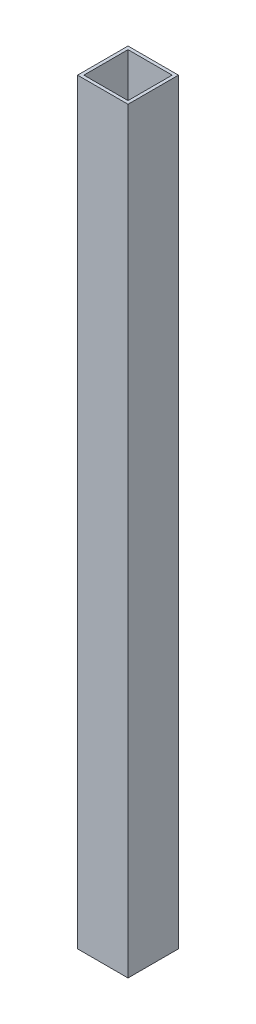
from build123d import *

# Parameters (mm, degrees)
SKETCH1_W           = 25.4
SKETCH1_H           = 25.4
SKETCH1_W_2         = 22.225
SKETCH1_H_2         = 22.225
BOSS_EXTRUDE1_DEPTH = 381


with BuildPart() as part:
    # Sketch1 → Boss-Extrude1 (new body)
    with BuildSketch(Plane(origin=(0, 0, 0), x_dir=(1, 0, 0), z_dir=(0, 1, 0))):
        Rectangle(SKETCH1_W, SKETCH1_H)
        Rectangle(SKETCH1_W_2, SKETCH1_H_2, mode=Mode.SUBTRACT)
    extrude(amount=BOSS_EXTRUDE1_DEPTH)


solid = part.part
